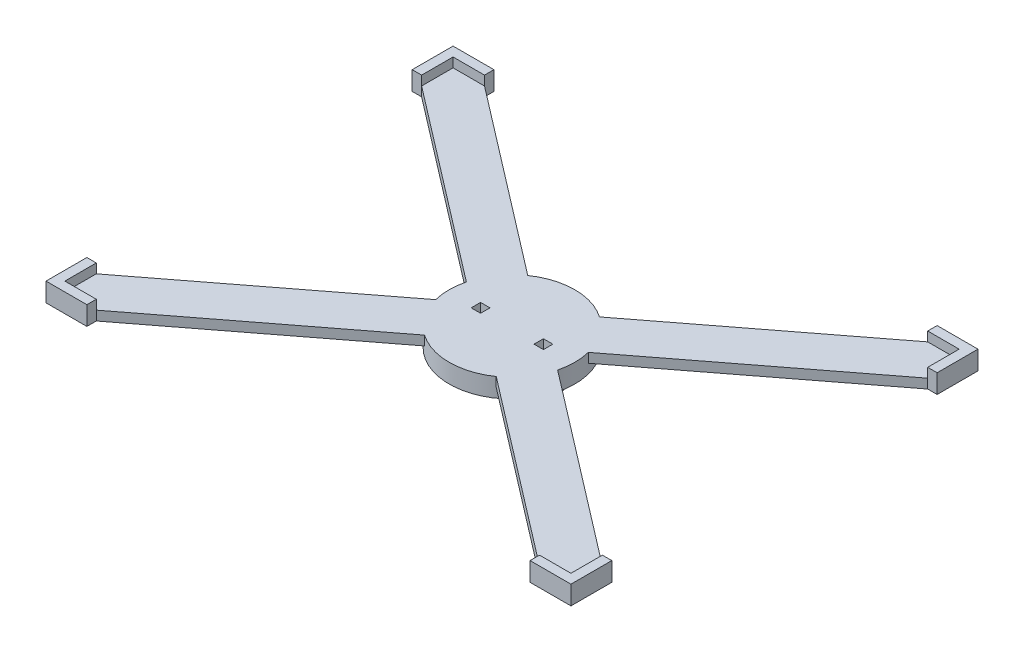
from build123d import *

# Parameters (mm, degrees)
SALIENTE_EXTRUIR1_DEPTH = 6
SALIENTE_EXTRUIR2_DEPTH = 12
CROQUIS7_R              = 40
SALIENTE_EXTRUIR5_DEPTH = 6
SALIENTE_EXTRUIR3_DEPTH = 6
CROQUIS6_R              = 1.75
SALIENTE_EXTRUIR4_DEPTH = 6
CROQUIS8_W              = 6
CROQUIS8_H              = 6
CORTAR_EXTRUIR1_DEPTH   = 31


with BuildPart() as part:
    # Croquis1 → Saliente-Extruir1 (new body)
    with BuildSketch(Plane(origin=(0, 0, 0), x_dir=(1, 0, 0), z_dir=(0, 1, 0))):
        with BuildLine():
            Line((-161, 103.5), (-38.791887254, 9.756509788))
            ThreePointArc((-38.791887254, 9.756509788), (-40, 0), (-38.791887254, -9.756509788))
            Line((-38.791887254, -9.756509788), (-161, -103.5))
            Line((-161, -103.5), (-161, -123.5))
            Line((-161, -123.5), (-141, -123.5))
            Line((-141, -123.5), (-22.823766962, -32.84928708))
            ThreePointArc((-22.823766962, -32.84928708), (0, -40), (22.823766962, -32.84928708))
            Line((22.823766962, -32.84928708), (141, -123.5))
            Line((141, -123.5), (161, -123.5))
            Line((161, -123.5), (161, -103.5))
            Line((161, -103.5), (38.791887254, -9.756509788))
            ThreePointArc((38.791887254, -9.756509788), (40, 0), (38.791887254, 9.756509788))
            Line((38.791887254, 9.756509788), (161, 103.5))
            Line((161, 103.5), (161, 123.5))
            Line((161, 123.5), (141, 123.5))
            Line((141, 123.5), (22.823766962, 32.84928708))
            ThreePointArc((22.823766962, 32.84928708), (0, 40), (-22.823766962, 32.84928708))
            Line((-22.823766962, 32.84928708), (-141, 123.5))
            Line((-141, 123.5), (-161, 123.5))
            Line((-161, 123.5), (-161, 103.5))
        make_face()
    extrude(amount=SALIENTE_EXTRUIR1_DEPTH)

    # Croquis4 → Saliente-Extruir2 (add)
    with BuildSketch(Plane(origin=(0, 0, 0), x_dir=(1, 0, 0), z_dir=(0, 1, 0))):
        Polygon((-161, 103.5), (-161, 123.5), (-141, 123.5), (-141, 129.5), (-167, 129.5), (-167, 103.5), align=None)
        Polygon((-161, -103.5), (-161, -123.5), (-141, -123.5), (-141, -129.5), (-167, -129.5), (-167, -103.5), align=None)
        Polygon((167, -103.5), (161, -103.5), (161, -123.5), (141, -123.5), (141, -129.5), (167, -129.5), align=None)
        Polygon((167, 103.5), (161, 103.5), (161, 123.5), (141, 123.5), (141, 129.5), (167, 129.5), align=None)
    extrude(amount=SALIENTE_EXTRUIR2_DEPTH)

    # Croquis7 → Saliente-Extruir5 (add)
    with BuildSketch(Plane(origin=(0, 0, 0), x_dir=(-1, 0, 0), z_dir=(0, -1, 0))):
        Circle(CROQUIS7_R)
    extrude(amount=SALIENTE_EXTRUIR5_DEPTH)

    # Croquis5 → Saliente-Extruir3 (add)
    with BuildSketch(Plane.XZ.offset(6)):
        with BuildLine():
            Line((18.896097481, -21), (-18.896097481, -21))
            ThreePointArc((-18.896097481, -21), (-28.25, 0), (-18.896097481, 21))
            Line((-18.896097481, 21), (-13.25, 21))
            Line((-13.25, 21), (-13.25, -11))
            Line((-13.25, -11), (13.25, -11))
            Line((13.25, -11), (13.25, 21))
            Line((13.25, 21), (18.896097481, 21))
            ThreePointArc((18.896097481, 21), (28.25, 0), (18.896097481, -21))
        make_face()
    extrude(amount=SALIENTE_EXTRUIR3_DEPTH)

    # Croquis6 → Saliente-Extruir4 (add)
    with BuildSketch(Plane.XZ.offset(12)):
        with BuildLine():
            Line((-18.896097481, 21), (-13.25, 21))
            Line((-13.25, 21), (-13.25, 3.5))
            ThreePointArc((-13.25, 3.5), (-13.103553391, 3.146446609), (-12.75, 3))
            Line((-12.75, 3), (12.75, 3))
            ThreePointArc((12.75, 3), (13.103553391, 3.146446609), (13.25, 3.5))
            Line((13.25, 3.5), (13.25, 21))
            Line((13.25, 21), (18.896097481, 21))
            ThreePointArc((18.896097481, 21), (28.25, 0), (18.896097481, -21))
            Line((18.896097481, -21), (-18.896097481, -21))
            ThreePointArc((-18.896097481, -21), (-28.25, 0), (-18.896097481, 21))
        make_face()
        with Locations((-8, -5.75)):
            Circle(CROQUIS6_R, mode=Mode.SUBTRACT)
        with Locations((8, -5.75)):
            Circle(CROQUIS6_R, mode=Mode.SUBTRACT)
    extrude(amount=SALIENTE_EXTRUIR4_DEPTH)

    # Croquis8 → Cortar-Extruir1 (cut, through all)
    with BuildSketch(Plane.XZ.offset(18)):
        with Locations((-20, 0)):
            Rectangle(CROQUIS8_W, CROQUIS8_H)
        with Locations((20, 0)):
            Rectangle(CROQUIS8_W, CROQUIS8_H)
    extrude(amount=-CORTAR_EXTRUIR1_DEPTH, mode=Mode.SUBTRACT)


solid = part.part
